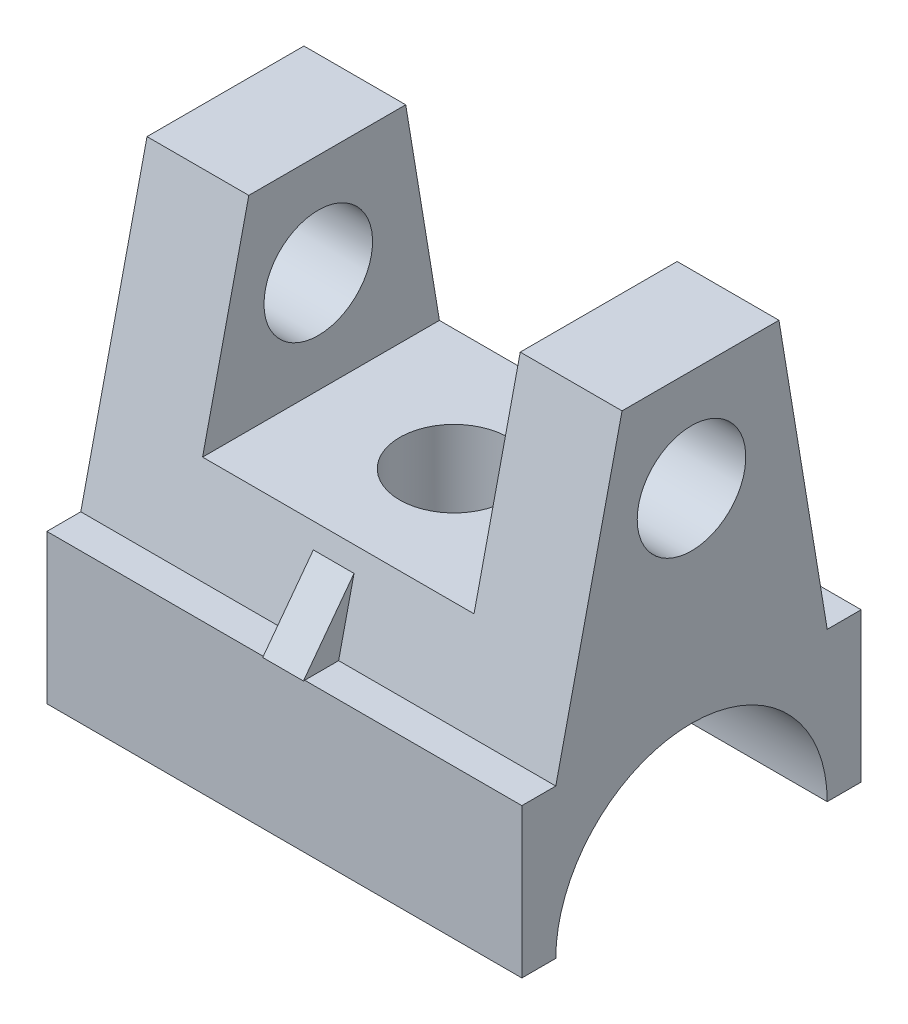
from build123d import *

# Parameters (mm, degrees)
SKETCH1_W               = 140
SKETCH1_H               = 100
BOSS_EXTRUDE1_DEPTH     = 44
CUT_EXTRUDE2_DEPTH      = 1
CUT_EXTRUDE2_DEPTH_BACK = 141
BOSS_EXTRUDE2_DEPTH     = 140
SKETCH5_W               = 80
SKETCH5_H               = 60
CUT_EXTRUDE3_DEPTH      = 1
CUT_EXTRUDE3_DEPTH_BACK = 101
SKETCH6_R               = 16
CUT_EXTRUDE4_DEPTH      = 61
CUT_EXTRUDE4_DEPTH_BACK = 71
SKETCH7_R               = 16
CUT_EXTRUDE5_DEPTH      = 1.0000001
CUT_EXTRUDE5_DEPTH_BACK = 141.0000001
BOSS_EXTRUDE6_DEPTH     = 6
BOSS_EXTRUDE7_DEPTH     = 6


with BuildPart() as part:
    # Sketch1 → Boss-Extrude1 (new body)
    with BuildSketch(Plane(origin=(0, 0, 0), x_dir=(1, 0, 0), z_dir=(0, 1, 0))):
        with Locations((70, 50)):
            Rectangle(SKETCH1_W, SKETCH1_H)
    extrude(amount=BOSS_EXTRUDE1_DEPTH)

    # Sketch2 → Cut-Extrude2 (cut, two sides)
    with BuildSketch(Plane.ZY) as cut_extrude2_sk:
        with BuildLine():
            Line((-90, -210.359676582), (-90, 0))
            ThreePointArc((-90, 0), (-50, 40), (-10, 0))
            Line((-10, 0), (-10, -210.359676582))
            Line((-10, -210.359676582), (-10, -631.079029746))
            Line((-10, -631.079029746), (-90, -631.079029746))
            Line((-90, -631.079029746), (-90, -210.359676582))
        make_face()
    extrude(amount=CUT_EXTRUDE2_DEPTH, mode=Mode.SUBTRACT)
    extrude(cut_extrude2_sk.sketch, amount=-CUT_EXTRUDE2_DEPTH_BACK, mode=Mode.SUBTRACT)

    # Sketch3 → Boss-Extrude2 (add)
    with BuildSketch(Plane.ZY):
        Polygon((-90, 44), (-75.775374972, 130), (-29.52448448, 130), (-10, 44), align=None)
    extrude(amount=-BOSS_EXTRUDE2_DEPTH)

    # Sketch5 → Cut-Extrude3 (cut, two sides)
    with BuildSketch(Plane.XY) as cut_extrude3_sk:
        with Locations((70, 100)):
            Rectangle(SKETCH5_W, SKETCH5_H)
    extrude(amount=CUT_EXTRUDE3_DEPTH, mode=Mode.SUBTRACT)
    extrude(cut_extrude3_sk.sketch, amount=-CUT_EXTRUDE3_DEPTH_BACK, mode=Mode.SUBTRACT)

    # Sketch6 → Cut-Extrude4 (cut, two sides)
    with BuildSketch(Plane(origin=(0, 70, 0), x_dir=(1, 0, 0), z_dir=(0, 1, 0))) as cut_extrude4_sk:
        with Locations((70, 50)):
            Circle(SKETCH6_R)
    extrude(amount=CUT_EXTRUDE4_DEPTH, mode=Mode.SUBTRACT)
    extrude(cut_extrude4_sk.sketch, amount=-CUT_EXTRUDE4_DEPTH_BACK, mode=Mode.SUBTRACT)

    # Sketch7 → Cut-Extrude5 (cut, two sides)
    with BuildSketch(Plane.ZY) as cut_extrude5_sk:
        with Locations((-50, 100)):
            Circle(SKETCH7_R)
    extrude(amount=CUT_EXTRUDE5_DEPTH, mode=Mode.SUBTRACT)
    extrude(cut_extrude5_sk.sketch, amount=-CUT_EXTRUDE5_DEPTH_BACK, mode=Mode.SUBTRACT)

    # Sketch15 → Boss-Extrude6 (add, symmetric)
    with BuildSketch(Plane.ZY.offset(-70)):
        Polygon((-14.540577786, 64), (-10, 44), (0.380318398, 44), align=None)
    extrude(amount=BOSS_EXTRUDE6_DEPTH, both=True)

    # Sketch17 → Boss-Extrude7 (add, symmetric)
    with BuildSketch(Plane.ZY.offset(-70)):
        Polygon((-86.691947668, 64), (-100.019037355, 44), (-90, 44), align=None)
    extrude(amount=BOSS_EXTRUDE7_DEPTH, both=True)


solid = part.part
